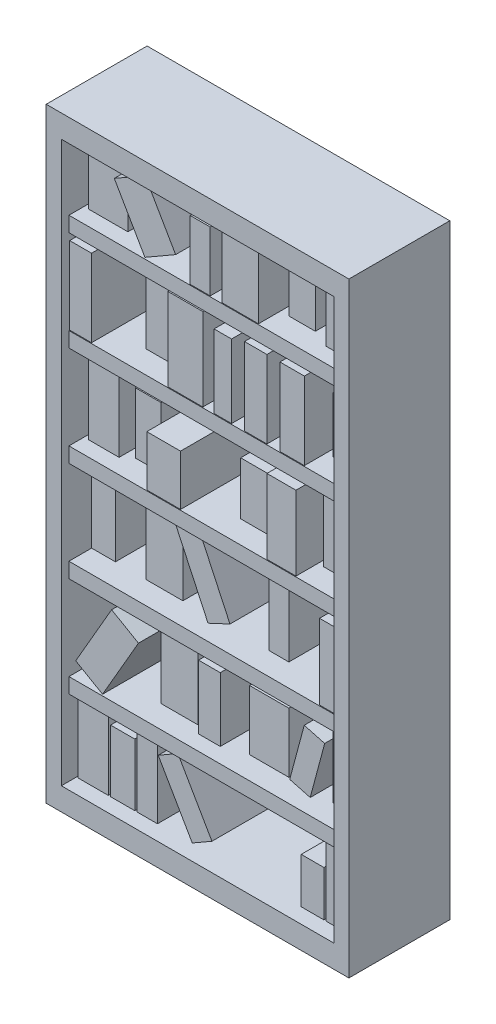
from build123d import *

# Parameters (mm, degrees)
SKETCH1_W           = 100
SKETCH1_H           = 33.333333334
BOSS_EXTRUDE1_DEPTH = 100
SKETCH2_W           = 90
SKETCH2_H           = 185
CUT_EXTRUDE1_DEPTH  = 27.5
SKETCH3_W           = 90
SKETCH3_H           = 5
BOSS_EXTRUDE2_DEPTH = 25
SKETCH4_W           = 7.5
SKETCH4_H           = 22.5
SKETCH4_H_2         = 15
SKETCH4_W_2         = 10
SKETCH4_W_3         = 8
SKETCH4_H_3         = 20.5
SKETCH4_W_4         = 6.75
BOSS_EXTRUDE5_DEPTH = 22.5
SKETCH5_W           = 10.245435458
SKETCH5_H           = 22.43939507
SKETCH5_W_2         = 12.999798951
SKETCH5_H_2         = 19.786374876
SKETCH5_W_3         = 12.203892893
SKETCH5_H_3         = 25.623019303
SKETCH5_W_4         = 7.857717283
SKETCH5_H_4         = 23.132751534
SKETCH5_W_5         = 12.203892892
SKETCH5_H_5         = 25
SKETCH5_W_6         = 6.632550485
SKETCH5_H_6         = 20.74503336
SKETCH5_W_7         = 10.346778757
SKETCH5_H_7         = 22.499597902
SKETCH5_W_8         = 12.601845922
SKETCH5_H_8         = 17.458859533
SKETCH5_W_9         = 8.489664621
SKETCH5_H_9         = 20.111879727
SKETCH5_H_10        = 18.417518017
SKETCH5_H_11        = 21.866444269
SKETCH5_W_10        = 8.75496664
SKETCH5_H_12        = 19.64147852
BOSS_EXTRUDE6_DEPTH = 17.5
SKETCH6_W           = 7.163154524
SKETCH6_H           = 21.112884973
SKETCH6_W_2         = 10.071772785
SKETCH6_H_2         = 24.928709858
SKETCH6_W_3         = 7.639556761
SKETCH6_H_3         = 23
SKETCH6_W_4         = 12.990267768
SKETCH6_H_4         = 19.731154058
BOSS_EXTRUDE7_DEPTH = 20
SKETCH7_W           = 7.443100334
SKETCH7_H           = 24.824572523
SKETCH7_W_2         = 11.141906558
SKETCH7_H_2         = 16.691268837
SKETCH7_W_3         = 9.597619028
SKETCH7_H_3         = 24.576310401
SKETCH7_W_4         = 7.222078614
SKETCH7_H_4         = 25.616891847
SKETCH7_W_5         = 11.567302571
SKETCH7_H_5         = 27.303769204
SKETCH7_W_6         = 5.774265567
SKETCH7_H_6         = 24.198791538
SKETCH7_W_7         = 7.404792338
SKETCH7_W_8         = 8.068151888
SKETCH7_W_9         = 12.035735356
SKETCH7_H_7         = 22.027016439
SKETCH7_W_10        = 6.605492776
SKETCH7_H_8         = 19.712859317
BOSS_EXTRUDE9_DEPTH = 24.75


with BuildPart() as part:
    # Sketch1 → Boss-Extrude1 (new body, symmetric)
    with BuildSketch(Plane(origin=(0, 0, 0), x_dir=(1, 0, 0), z_dir=(0, 1, 0))):
        Rectangle(SKETCH1_W, SKETCH1_H)
    extrude(amount=BOSS_EXTRUDE1_DEPTH, both=True)

    # Sketch2 → Cut-Extrude1 (cut)
    with BuildSketch(Plane.XY.offset(16.666666667)):
        Rectangle(SKETCH2_W, SKETCH2_H)
    extrude(amount=-CUT_EXTRUDE1_DEPTH, mode=Mode.SUBTRACT)

    # Sketch3 → Boss-Extrude2 (add)
    with BuildSketch(Plane.XY.offset(-10.833333333)):
        with Locations((0, -65)):
            Rectangle(SKETCH3_W, SKETCH3_H)
        with Locations((0, -32)):
            Rectangle(SKETCH3_W, SKETCH3_H)
        with Locations((0, 1)):
            Rectangle(SKETCH3_W, SKETCH3_H)
        with Locations((0, 34)):
            Rectangle(SKETCH3_W, SKETCH3_H)
        with Locations((0, 67)):
            Rectangle(SKETCH3_W, SKETCH3_H)
    extrude(amount=BOSS_EXTRUDE2_DEPTH)

    # Sketch4 → Boss-Extrude5 (add)
    with BuildSketch(Plane.XY.offset(-10.833333333)):
        with Locations((41.25, -81.25)):
            Rectangle(SKETCH4_W, SKETCH4_H)
        with Locations((33, -85)):
            Rectangle(SKETCH4_W, SKETCH4_H_2)
        with Locations((-39.5, -81.25)):
            Rectangle(SKETCH4_W_2, SKETCH4_H)
        with Locations((-29.7477, -82.25)):
            Rectangle(SKETCH4_W_3, SKETCH4_H_3)
        with Locations((-21.6227, -81.25)):
            Rectangle(SKETCH4_W_4, SKETCH4_H)
        Polygon((-17.9977, -72.764428415), (-6.7477, -92.25), (-0.252509472, -88.5), (-11.502509472, -69.014428415), align=None)
    extrude(amount=BOSS_EXTRUDE5_DEPTH)

    # Sketch5 → Boss-Extrude6 (add)
    with BuildSketch(Plane.XY.offset(-10.833333333)):
        with Locations((39.877282271, -51.280302465)):
            Rectangle(SKETCH5_W, SKETCH5_H)
        with Locations((13.663054, -52.606812562)):
            Rectangle(SKETCH5_W_2, SKETCH5_H_2)
        with Locations((-15.918121165, -49.688490349)):
            Rectangle(SKETCH5_W_3, SKETCH5_H_3)
        with Locations((-41.071141359, -17.933624233)):
            Rectangle(SKETCH5_W_4, SKETCH5_H_4)
        with Locations((-20.958859533, -17)):
            Rectangle(SKETCH5_W_5, SKETCH5_H_5)
        with Locations((16.846678233, -19.12748332)):
            Rectangle(SKETCH5_W_6, SKETCH5_H_6)
        with Locations((36.826610622, 14.749798951)):
            Rectangle(SKETCH5_W_7, SKETCH5_H_7)
        with Locations((10.545755271, 12.229429767)):
            Rectangle(SKETCH5_W_8, SKETCH5_H_8)
        with Locations((-26.264899922, 13.555939864)):
            Rectangle(SKETCH5_W_9, SKETCH5_H_9)
        with Locations((39.877282271, 45.708759009)):
            Rectangle(SKETCH5_W, SKETCH5_H_10)
        with Locations((-20.958859533, 47.433222134)):
            Rectangle(SKETCH5_W_5, SKETCH5_H_11)
        with Locations((24.540436795, 79.32073926)):
            Rectangle(SKETCH5_W_10, SKETCH5_H_12)
    extrude(amount=BOSS_EXTRUDE6_DEPTH)

    # Sketch6 → Boss-Extrude7 (add)
    with BuildSketch(Plane.XY.offset(-10.833333333)):
        with Locations((-3.581577262, -51.943557514)):
            Rectangle(SKETCH6_W, SKETCH6_H)
        Polygon((27.743083758, -42.568638898), (34.504564542, -44.380372214), (29.716412208, -62.25), (22.954931424, -60.438266684), align=None)
        Polygon((-14.606913087, -6.592305324), (-4.041456543, -29.25), (3.209005753, -25.869053906), (-7.35645079, -3.21135923), align=None)
        with Locations((-38.464113607, 15.964354929)):
            Rectangle(SKETCH6_W_2, SKETCH6_H_2)
        with Locations((38.68022162, 81)):
            Rectangle(SKETCH6_W_3, SKETCH6_H_3)
        with Locations((-37.004866116, 79.365577029)):
            Rectangle(SKETCH6_W_4, SKETCH6_H_4)
    extrude(amount=BOSS_EXTRUDE7_DEPTH)

    # Sketch7 → Boss-Extrude9 (add)
    with BuildSketch(Plane.XY.offset(-10.833333333)):
        Polygon((-22.270067611, -41.703177725), (-31.144265017, -36.579657463), (-43.006978388, -57.126479739), (-34.132780982, -62.25), align=None)
        with Locations((41.278449833, -17.087713739)):
            Rectangle(SKETCH7_W, SKETCH7_H)
        with Locations((-13.949114332, 11.845634419)):
            Rectangle(SKETCH7_W_2, SKETCH7_H_2)
        with Locations((24.961762989, 15.788155201)):
            Rectangle(SKETCH7_W_3, SKETCH7_H_3)
        with Locations((-41.388960693, 49.308445924)):
            Rectangle(SKETCH7_W_4, SKETCH7_H_4)
        with Locations((-6.788808075, 50.151884602)):
            Rectangle(SKETCH7_W_5, SKETCH7_H_5)
        with Locations((5.599653825, 48.599395769)):
            Rectangle(SKETCH7_W_6, SKETCH7_H_6)
        with Locations((16.460557306, 49.308445924)):
            Rectangle(SKETCH7_W_7, SKETCH7_H_4)
        with Locations((28.498967272, 49.308445924)):
            Rectangle(SKETCH7_W_8, SKETCH7_H_4)
        Polygon((-30.259732232, 87.284915382), (-20.135944116, 69.75), (-9.994868577, 75.604952692), (-20.118656693, 93.139868074), align=None)
        with Locations((11.35767736, 80.51350822)):
            Rectangle(SKETCH7_W_9, SKETCH7_H_7)
        with Locations((-1.87064299, 79.356429659)):
            Rectangle(SKETCH7_W_10, SKETCH7_H_8)
    extrude(amount=BOSS_EXTRUDE9_DEPTH)


solid = part.part
